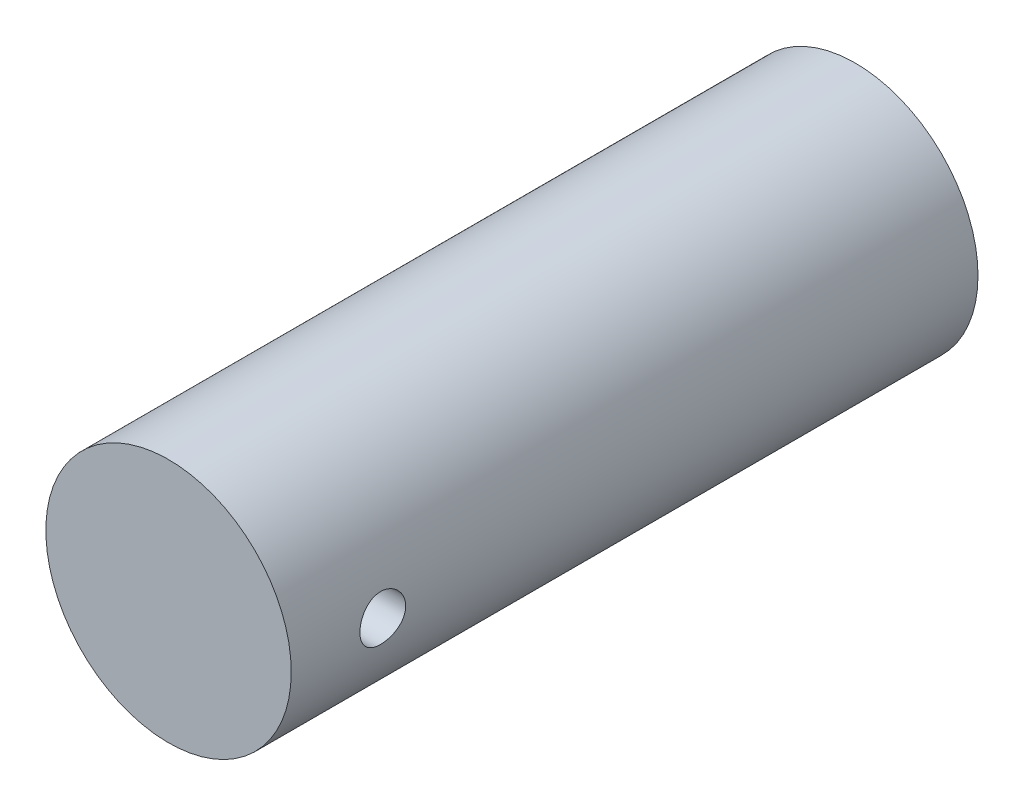
from build123d import *

# Parameters (mm, degrees)
SKETCH1_R               = 8.509
BOSS_EXTRUDE1_DEPTH     = 47.625
CUT_EXTRUDE1_DEPTH      = 47.625
CUT_EXTRUDE1_DEPTH_BACK = 47.625
SKETCH2_R               = 1.5875


with BuildPart() as part:
    # Sketch1 → Boss-Extrude1 (new body)
    with BuildSketch(Plane.XY):
        Circle(SKETCH1_R)
    extrude(amount=BOSS_EXTRUDE1_DEPTH)

    # Sketch2 → Cut-Extrude1 (cut, two sides: drawn at the far end of the back side and taken through both)
    with BuildSketch(Plane(origin=(0, 0, 0), x_dir=(0, 0, -1), z_dir=(1, 0, 0)).offset(-CUT_EXTRUDE1_DEPTH_BACK)):
        with Locations((-41.275, 0)):
            Circle(SKETCH2_R)
    extrude(amount=CUT_EXTRUDE1_DEPTH + CUT_EXTRUDE1_DEPTH_BACK, mode=Mode.SUBTRACT)


solid = part.part
